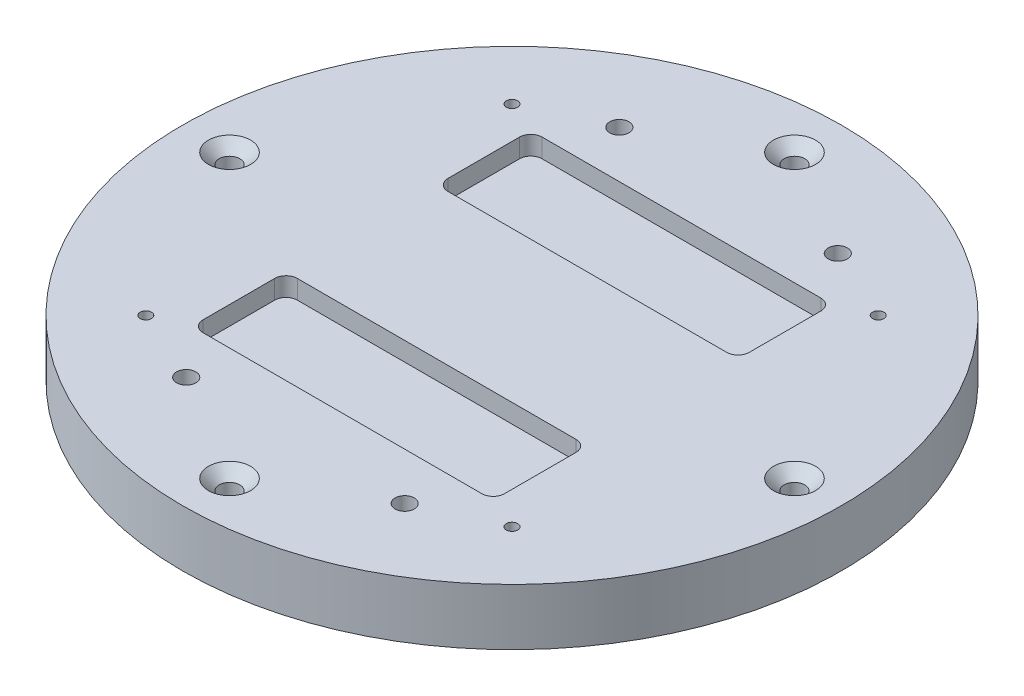
from build123d import *

# Parameters (mm, degrees)
SKETCH1_R                              = 175
BOSS_EXTRUDE1_DEPTH                    = 30
CSK_FOR_M10_SFHCS1_D                   = 11
CSK_FOR_M10_SFHCS1_CSINK_D             = 22.4
CSK_FOR_M10_SFHCS1_CSINK_ANGLE         = 90
F_6_0MM_DOWEL_HOLE1_D                  = 6
CUT_EXTRUDE2_DEPTH                     = 10
TAP_DRILL_FOR_M12X1_75_TAP1_AT_2_COUNT = 2
TAP_DRILL_FOR_M12X1_75_TAP1_AT_2_PITCH = 116
TAP_DRILL_FOR_M12X1_75_TAP1_AT_3_COUNT = 2
TAP_DRILL_FOR_M12X1_75_TAP1_AT_3_PITCH = 257.596583828
TAP_DRILL_FOR_M12X1_75_TAP1_AT_4_COUNT = 2
TAP_DRILL_FOR_M12X1_75_TAP1_AT_4_PITCH = 230


with BuildPart() as part:
    # Sketch1 → Boss-Extrude1 (new body)
    with BuildSketch(Plane(origin=(0, 0, 0), x_dir=(1, 0, 0), z_dir=(0, 1, 0))):
        Circle(SKETCH1_R)
    extrude(amount=BOSS_EXTRUDE1_DEPTH)

    # CSK for M10 SFHCS1 (through all)
    with Locations(Plane(origin=(0, 30, 0), x_dir=(1, 0, 0), z_dir=(0, 1, 0))):
        with Locations((-150, 0), (0, -150), (150, 0), (0, 150)):
            CounterSinkHole(CSK_FOR_M10_SFHCS1_D / 2, CSK_FOR_M10_SFHCS1_CSINK_D / 2, counter_sink_angle=CSK_FOR_M10_SFHCS1_CSINK_ANGLE)

    # Ø6.0mm Dowel Hole1 (through all)
    with Locations(Plane(origin=(0, 30, 0), x_dir=(1, 0, 0), z_dir=(0, 1, 0))):
        with Locations((-97.227182413, -97.227182413), (97.227182413, -97.227182413), (97.227182413, 97.227182413), (-97.227182413, 97.227182413)):
            Hole(F_6_0MM_DOWEL_HOLE1_D / 2)

    # Sketch14 → Cut-Extrude2 (cut)
    with BuildSketch(Plane(origin=(0, 30, 0), x_dir=(1, 0, 0), z_dir=(0, 1, 0))):
        with BuildLine():
            Line((-74, -40), (74, -40))
            ThreePointArc((74, -40), (78.242640687, -41.757359313), (80, -46))
            Line((80, -46), (80, -84))
            ThreePointArc((80, -84), (78.242640687, -88.242640687), (74, -90))
            Line((74, -90), (-74, -90))
            ThreePointArc((-74, -90), (-78.242640687, -88.242640687), (-80, -84))
            Line((-80, -84), (-80, -46))
            ThreePointArc((-80, -46), (-78.242640687, -41.757359313), (-74, -40))
        make_face()
        with BuildLine():
            Line((80, 46), (80, 84))
            ThreePointArc((80, 84), (78.242640687, 88.242640687), (74, 90))
            Line((74, 90), (-74, 90))
            ThreePointArc((-74, 90), (-78.242640687, 88.242640687), (-80, 84))
            Line((-80, 84), (-80, 46))
            ThreePointArc((-80, 46), (-78.242640687, 41.757359313), (-74, 40))
            Line((-74, 40), (74, 40))
            ThreePointArc((74, 40), (78.242640687, 41.757359313), (80, 46))
        make_face()
    extrude(amount=-CUT_EXTRUDE2_DEPTH, mode=Mode.SUBTRACT)

    # Sketch21 → Tap Drill for M12x1.75 Tap1 (revolve, cut)
    with BuildSketch(Plane(origin=(-58, 30, -115), x_dir=(0, 0, 1), z_dir=(1, 0, 0))):
        Polygon((0, 0), (0, 30), (12.5, 30), (5.1, 19.43170475), (5.1, 0), align=None)
    tap_drill_for_m12x1_75_tap1 = revolve(axis=Axis((-58, 36.35, -115), (0, -1, 0)), mode=Mode.SUBTRACT)

    # Tap Drill for M12x1.75 Tap1 at 2: Tap Drill for M12x1.75 Tap1 ×2
    with Locations(*[(i * TAP_DRILL_FOR_M12X1_75_TAP1_AT_2_PITCH, 0, 0) for i in range(1, TAP_DRILL_FOR_M12X1_75_TAP1_AT_2_COUNT)]):
        add(tap_drill_for_m12x1_75_tap1, mode=Mode.SUBTRACT)

    # Tap Drill for M12x1.75 Tap1 at 3: Tap Drill for M12x1.75 Tap1 ×2
    with Locations(*[Vector(0.450316531, 0, 0.892868984) * (i * TAP_DRILL_FOR_M12X1_75_TAP1_AT_3_PITCH) for i in range(1, TAP_DRILL_FOR_M12X1_75_TAP1_AT_3_COUNT)]):
        add(tap_drill_for_m12x1_75_tap1, mode=Mode.SUBTRACT)

    # Tap Drill for M12x1.75 Tap1 at 4: Tap Drill for M12x1.75 Tap1 ×2
    with Locations(*[(0, 0, i * TAP_DRILL_FOR_M12X1_75_TAP1_AT_4_PITCH) for i in range(1, TAP_DRILL_FOR_M12X1_75_TAP1_AT_4_COUNT)]):
        add(tap_drill_for_m12x1_75_tap1, mode=Mode.SUBTRACT)


solid = part.part
